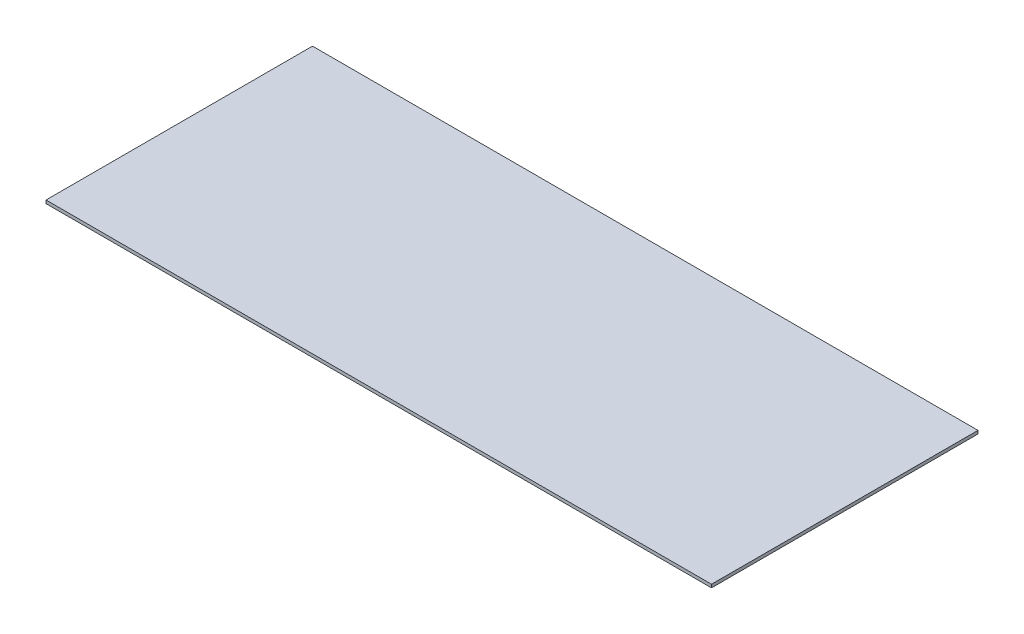
from build123d import *

# Parameters (mm, degrees)
SKETCH4_W           = 5867.4
SKETCH4_H           = 2349.5
BOSS_EXTRUDE2_DEPTH = 27.94


with BuildPart() as part:
    # Sketch4 → Boss-Extrude2 (new body)
    with BuildSketch(Plane(origin=(0, 0, 0), x_dir=(1, 0, 0), z_dir=(0, 1, 0))):
        with Locations((2933.7, 1174.75)):
            Rectangle(SKETCH4_W, SKETCH4_H)
    extrude(amount=-BOSS_EXTRUDE2_DEPTH)


solid = part.part
